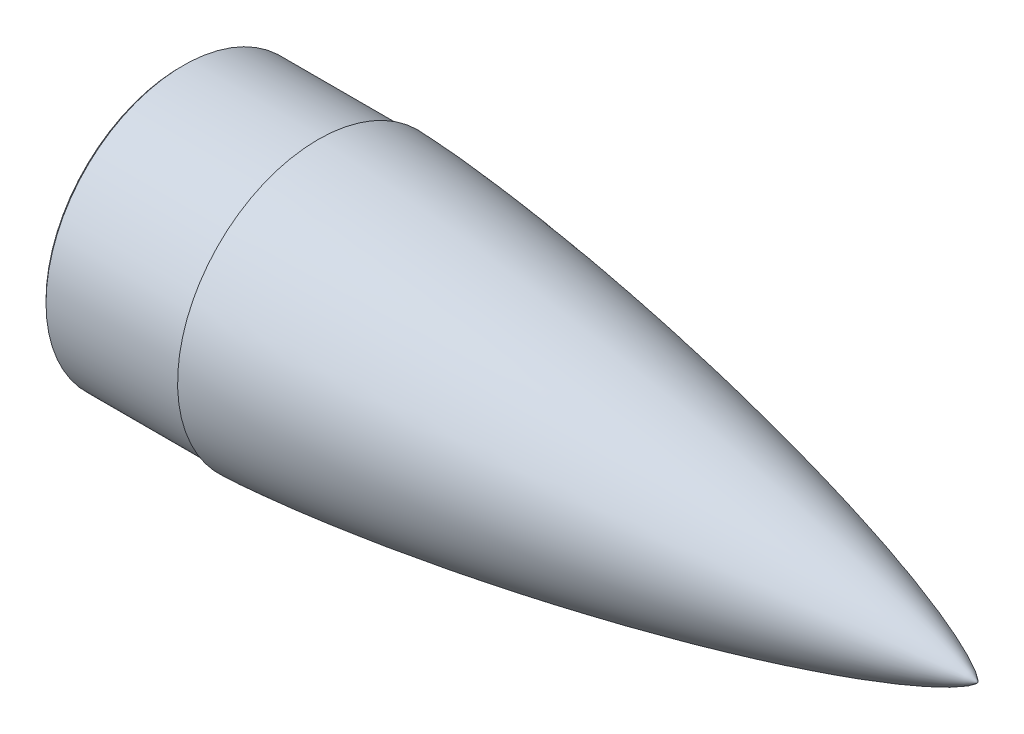
from build123d import *

# Parameters (mm, degrees)
CHAMFER1_SIZE = 1.5


with BuildPart() as part:
    # Sketch10 → Revolve1 (revolve)
    with BuildSketch(Plane.XY):
        with BuildLine():
            Line((11.112493743, 81.99983), (-84.604517473, 81.99983))
            Line((-84.604517473, 81.99983), (-84.604517473, 84.99983))
            Line((-84.604517473, 84.99983), (0.395312527, 84.99983))
            Line((0.395312527, 84.99983), (0.395312527, 86.99983))
            add(Edge.make_bspline(
                [(408.967251823, 0), (408.964913524, 0.013501739), (408.958040758, 0.039916077), (408.936520441, 0.090485698), (408.892222076, 0.174057132), (408.826281575, 0.275556803), (408.721696416, 0.415833756), (408.561101809, 0.605075245), (408.30561918, 0.87242415), (407.86966713, 1.275299562), (407.120955138, 1.885142115), (405.803773451, 2.82590185), (403.46240692, 4.287152794), (399.325294488, 6.531818454), (392.481146888, 9.758904649), (380.662076725, 14.628008466), (363.637187185, 20.711720382), (342.215241093, 27.476512989), (317.428462321, 34.49762647), (291.879335737, 41.10482439), (266.21046092, 47.228993169), (240.44548836, 52.933436777), (214.598861982, 58.255439009), (188.68089566, 63.217582693), (165.946174917, 67.253280679), (146.421982586, 70.493799722), (130.127893898, 73.044947468), (117.078590637, 74.994157933), (104.015464216, 76.84854079), (92.573263959, 78.384492045), (82.757139441, 79.635603973), (74.571340184, 80.632219902), (68.019260454, 81.400804211), (61.463723364, 82.139375899), (54.90469802, 82.84637726), (48.342159918, 83.519940506), (41.776057559, 84.15778717), (36.02754108, 84.682157239), (31.097921259, 85.105234912), (26.988317923, 85.438669825), (23.699666618, 85.693218594), (20.085807822, 85.958448038), (16.719873821, 86.189018485), (13.602098287, 86.386966779), (10.732704013, 86.554575744), (8.436635008, 86.678703291), (6.139997341, 86.792157585), (4.129892063, 86.879313264), (2.40653858, 86.944618982), (1.257348635, 86.979022496), (0.68269791, 86.99491462), (0.395312527, 86.99983)],
                knots=[0, 0, 0, 0, 0, 0.000130123, 0.000260245, 0.000520491, 0.000900391, 0.00128029, 0.001925099, 0.002881508, 0.004418208, 0.006927086, 0.011110697, 0.018279138, 0.03067276, 0.051704469, 0.08310228, 0.139908797, 0.202702513, 0.265496165, 0.328289682, 0.391083359, 0.453876973, 0.516670577, 0.579464197, 0.642257765, 0.673654596, 0.705051427, 0.736448267, 0.767845106, 0.799241874, 0.814940257, 0.830638641, 0.846337073, 0.862035505, 0.877733936, 0.893432368, 0.90913072, 0.924829072, 0.932678248, 0.940527424, 0.9483766, 0.956225776, 0.967169332, 0.97264111, 0.978112888, 0.983584666, 0.989056444, 0.994528222, 0.997264111, 1, 1, 1, 1, 1], degree=4))
            Line((408.967251823, 0), (368.967251823, 0))
            add(Edge.make_bspline(
                [(368.967251823, 0), (368.965299543, 0.012338489), (368.959416882, 0.036518378), (368.940636147, 0.082964007), (368.902304552, 0.158736421), (368.845538097, 0.250270687), (368.755690124, 0.376555746), (368.616653262, 0.54835284), (368.392888737, 0.793577299), (368.008659121, 1.164904965), (367.344738263, 1.729853685), (366.176060796, 2.601559154), (364.09282389, 3.960032328), (360.425978756, 6.040734396), (354.402196649, 9.01831007), (344.042994901, 13.507695011), (329.152005398, 19.128483965), (310.425167902, 25.398569259), (288.741266406, 31.933693508), (266.378532845, 38.106125474), (243.901379123, 43.846895186), (221.331994001, 49.212017941), (198.683967629, 54.234500927), (175.966897581, 58.934255644), (156.034567874, 62.771715365), (141.509051931, 65.395628269), (132.679425236, 66.924517444), (129.562757303, 67.455859883), (129.304508698, 67.49983)],
                knots=[0, 0, 0, 0, 0, 0.000134949, 0.000269899, 0.000539798, 0.000919537, 0.001299277, 0.001947431, 0.00293136, 0.004511869, 0.007081312, 0.011380263, 0.018707867, 0.031423867, 0.052705479, 0.084103008, 0.140910136, 0.203703492, 0.266497064, 0.329290816, 0.392084375, 0.454877964, 0.517671564, 0.580465191, 0.643258828, 0.674655593, 0.677492072, 0.677492072, 0.677492072, 0.677492072, 0.677492072], degree=4))
            ThreePointArc((129.304508698, 67.49983), (70.377361693, 76.126240996), (11.112493743, 81.99983))
        make_face()
    revolve(axis=Axis((46.917858469, 0, 0), (-1, 0, 0)))

    # Chamfer1
    chamfer1_edges = [part.edges().sort_by_distance(p)[0] for p in [
        (-84.604517473, -84.99983, 0),
    ]]
    chamfer(chamfer1_edges, length=CHAMFER1_SIZE)


solid = part.part
